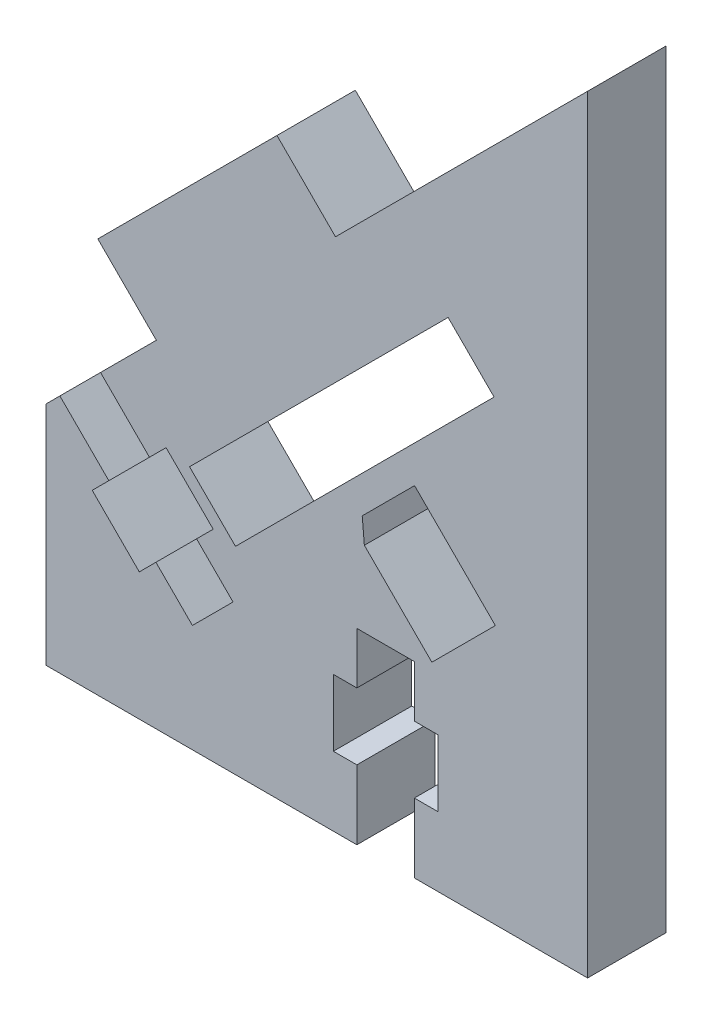
from build123d import *

# Parameters (mm, degrees)
RESSALTO_EXTRUS_O1_DEPTH = 6


with BuildPart() as part:
    # Model → Ressalto-extrusão1 (new body)
    with BuildSketch(Plane.XY):
        Polygon((36.978091014, 23.513650985), (35.70530016, 22.240860131), (39.311542875, 18.634617416), (40.584333729, 19.90740827), (43.377405166, 17.114336834), (46.488678057, 20.225609725), (43.695606621, 23.018681162), (44.968397475, 24.291472016), (41.36215476, 27.897714731), (40.089363906, 26.624923877), (36.341699099, 30.372588684), (40.614784991, 34.645674576), (36.134425304, 39.126034262), (49.852292818, 52.843901776), (54.332652505, 48.36354209), (73.636667559, 67.667557144), (73.636667559, 8.867561848), (60.3697662, 8.867561848), (60.3697662, 14.167560246), (62.169764288, 14.167560246), (62.169764288, 19.267557602), (60.3697662, 19.267557602), (60.3697662, 23.217557109), (55.96976188, 23.217557109), (55.96976188, 19.267557602), (54.169763792, 19.267557602), (54.169763792, 14.167560246), (55.96976188, 14.167560246), (55.96976188, 8.867561848), (32.16976612, 8.867561848), (32.16976612, 26.200655705), (33.230426207, 27.261315792), align=None)
        Polygon((60.386985649, 34.892299852), (66.57416949, 28.705116012), (61.712810758, 23.84375728), (56.542974359, 29.013593679), (56.37928278, 30.884596983), align=None, mode=Mode.SUBTRACT)
        Polygon((46.676618489, 24.010359591), (66.475606779, 43.80934788), (62.956288895, 47.328665763), (43.157300606, 27.529677474), align=None, mode=Mode.SUBTRACT)
    extrude(amount=RESSALTO_EXTRUS_O1_DEPTH)


solid = part.part
